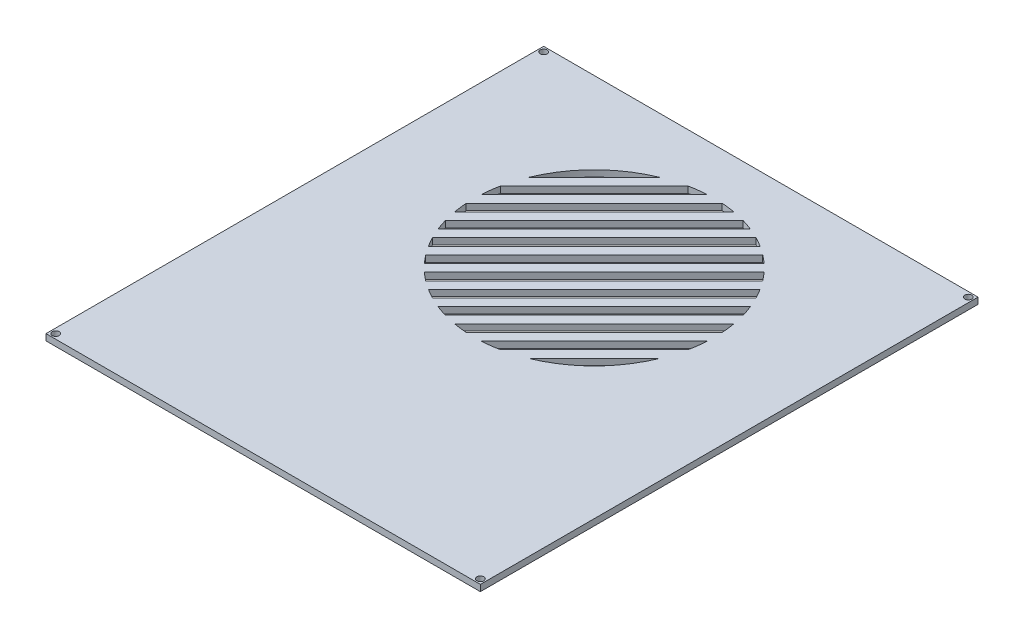
from build123d import *

# Parameters (mm, degrees)
SKIZZE1_W                       = 206
SKIZZE1_H                       = 236
AUFSATZ_LINEAR_AUSTRAGEN1_DEPTH = 3
SCHNITT_LINEAR_AUSTRAGEN2_DEPTH = 3
SKIZZE3_R                       = 1.65
SCHNITT_LINEAR_AUSTRAGEN3_DEPTH = 3


with BuildPart() as part:
    # Skizze1 → Aufsatz-Linear austragen1 (new body)
    with BuildSketch(Plane(origin=(0, 0, 0), x_dir=(1, 0, 0), z_dir=(0, 1, 0))):
        Rectangle(SKIZZE1_W, SKIZZE1_H)
    extrude(amount=AUFSATZ_LINEAR_AUSTRAGEN1_DEPTH)

    # Skizze2 → Schnitt-Linear austragen2 (cut)
    with BuildSketch(Plane(origin=(0, 3, 0), x_dir=(1, 0, 0), z_dir=(0, 1, 0))):
        with BuildLine():
            ThreePointArc((-21.427553093, 91.819125025), (-40.305086528, 79.305086528), (-52.819125025, 60.427553093))
            Line((-52.819125025, 60.427553093), (-21.427553093, 91.819125025))
        make_face()
        with BuildLine():
            ThreePointArc((-55.866928677, 50.30868163), (-56.534459002, 46.27014067), (-56.910435609, 42.194106886))
            Line((-56.910435609, 42.194106886), (-3.194106886, 95.910435609))
            ThreePointArc((-3.194106886, 95.910435609), (-7.27014067, 95.534459002), (-11.30868163, 94.866928677))
            Line((-11.30868163, 94.866928677), (-55.866928677, 50.30868163))
        make_face()
        with BuildLine():
            ThreePointArc((-56.870693274, 35.162781409), (-56.569218878, 32.005468167), (-56.092595564, 28.869811308))
            Line((-56.092595564, 28.869811308), (10.130188692, 95.092595564))
            ThreePointArc((10.130188692, 95.092595564), (6.994531833, 95.569218878), (3.837218591, 95.870693274))
            Line((3.837218591, 95.870693274), (-56.870693274, 35.162781409))
        make_face()
        with BuildLine():
            ThreePointArc((-54.749577763, 23.141761296), (-53.910125432, 20.487885699), (-52.942116187, 17.878155061))
            Line((-52.942116187, 17.878155061), (21.121844939, 91.942116187))
            ThreePointArc((21.121844939, 91.942116187), (18.512114301, 92.910125432), (15.858238704, 93.749577763))
            Line((15.858238704, 93.749577763), (-54.749577763, 23.141761296))
        make_face()
        with BuildLine():
            ThreePointArc((-50.733032764, 13.016170672), (-49.499198499, 10.736430728), (-48.162990305, 8.515145319))
            Line((-48.162990305, 8.515145319), (30.484854681, 87.162990305))
            ThreePointArc((30.484854681, 87.162990305), (28.263569272, 88.499198499), (25.983829328, 89.733032764))
            Line((25.983829328, 89.733032764), (-50.733032764, 13.016170672))
        make_face()
        with BuildLine():
            ThreePointArc((-45.258164778, 4.348903034), (-43.688596063, 2.389802322), (-42.034290815, 0.501709185))
            Line((-42.034290815, 0.501709185), (38.498290815, 81.034290815))
            ThreePointArc((38.498290815, 81.034290815), (36.610197678, 82.688596063), (34.651096966, 84.258164778))
            Line((34.651096966, 84.258164778), (-45.258164778, 4.348903034))
        make_face()
        with BuildLine():
            Line((42.034290815, 77.498290815), (-38.498290815, -3.034290815))
            ThreePointArc((-38.498290815, -3.034290815), (-36.610197678, -4.688596063), (-34.651096966, -6.258164778))
            Line((-34.651096966, -6.258164778), (45.258164778, 73.651096966))
            ThreePointArc((45.258164778, 73.651096966), (43.688596063, 75.610197678), (42.034290815, 77.498290815))
        make_face()
        with BuildLine():
            Line((48.162990305, 69.484854681), (-30.484854681, -9.162990305))
            ThreePointArc((-30.484854681, -9.162990305), (-28.263569272, -10.499198499), (-25.983829328, -11.733032764))
            Line((-25.983829328, -11.733032764), (50.733032764, 64.983829328))
            ThreePointArc((50.733032764, 64.983829328), (49.499198499, 67.263569272), (48.162990305, 69.484854681))
        make_face()
        with BuildLine():
            Line((52.942116187, 60.121844939), (-21.121844939, -13.942116187))
            ThreePointArc((-21.121844939, -13.942116187), (-18.512114301, -14.910125432), (-15.858238704, -15.749577763))
            Line((-15.858238704, -15.749577763), (54.749577763, 54.858238704))
            ThreePointArc((54.749577763, 54.858238704), (53.910125432, 57.512114301), (52.942116187, 60.121844939))
        make_face()
        with BuildLine():
            Line((56.092595564, 49.130188692), (-10.130188692, -17.092595564))
            ThreePointArc((-10.130188692, -17.092595564), (-6.994531833, -17.569218878), (-3.837218591, -17.870693274))
            Line((-3.837218591, -17.870693274), (56.870693274, 42.837218591))
            ThreePointArc((56.870693274, 42.837218591), (56.569218878, 45.994531833), (56.092595564, 49.130188692))
        make_face()
        with BuildLine():
            Line((56.910435609, 35.805893114), (3.194106886, -17.910435609))
            ThreePointArc((3.194106886, -17.910435609), (7.27014067, -17.534459002), (11.30868163, -16.866928677))
            Line((11.30868163, -16.866928677), (55.866928677, 27.69131837))
            ThreePointArc((55.866928677, 27.69131837), (56.534459002, 31.72985933), (56.910435609, 35.805893114))
        make_face()
        with BuildLine():
            Line((52.819125025, 17.572446907), (21.427553093, -13.819125025))
            ThreePointArc((21.427553093, -13.819125025), (40.305086528, -1.305086528), (52.819125025, 17.572446907))
        make_face()
    extrude(amount=-SCHNITT_LINEAR_AUSTRAGEN2_DEPTH, mode=Mode.SUBTRACT)

    # Skizze3 → Schnitt-Linear austragen3 (cut)
    with BuildSketch(Plane(origin=(0, 3, 0), x_dir=(1, 0, 0), z_dir=(0, 1, 0))):
        with Locations((-100.7, 115.7)):
            Circle(SKIZZE3_R)
        with Locations((100.7, 115.7)):
            Circle(SKIZZE3_R)
        with Locations((100.7, -115.7)):
            Circle(SKIZZE3_R)
        with Locations((-100.7, -115.7)):
            Circle(SKIZZE3_R)
    extrude(amount=-SCHNITT_LINEAR_AUSTRAGEN3_DEPTH, mode=Mode.SUBTRACT)


solid = part.part
